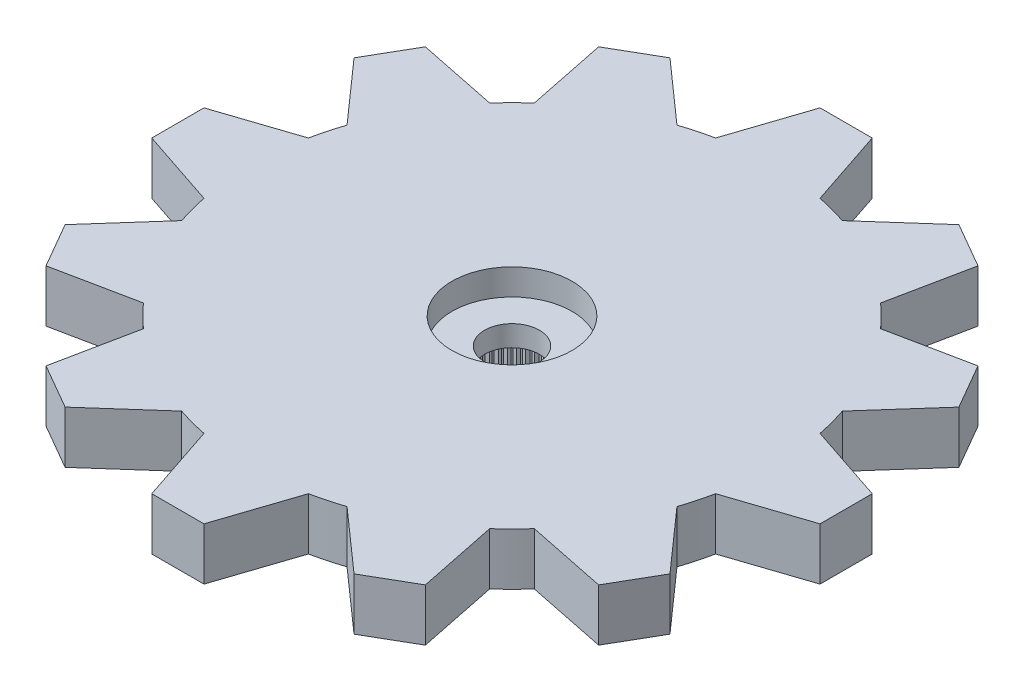
from build123d import *

# Parameters (mm, degrees)
RESSALTO_EXTRUS_O1_DEPTH = 1.4
ESBO_O2_R                = 3.45
RESSALTO_EXTRUS_O2_DEPTH = 2.4
FURO4_D                  = 1.2
PADR_O_LINEAR1_COUNT     = 6
PADR_O_LINEAR1_PITCH     = 2
PADR_OCIRCULAR2_COUNT    = 2
PADR_OCIRCULAR2_COPY_1_D = 1.2
PADR_OCIRCULAR2_COPY_2_D = 1.2
PADR_OCIRCULAR2_COPY_3_D = 1.2
PADR_OCIRCULAR2_COPY_4_D = 1.2
PADR_OCIRCULAR2_COPY_5_D = 1.2
FURO1_D                  = 4.95
FURO1_DEPTH              = 2
FURO2_D                  = 4.6
FURO2_DEPTH              = 1
FURO3_D                  = 2.1
RESSALTO_EXTRUS_O3_DEPTH = 2
PADR_OCIRCULAR1_COUNT    = 60
SKETCH2_W                = 33
SKETCH2_H                = 17
SKETCH2_R                = 3.45
CUT_EXTRUDE1_DEPTH       = 10
SKETCH3_R                = 10
SKETCH3_R_2              = 3.45
BOSS_EXTRUDE1_DEPTH      = 2
BOSS_EXTRUDE2_DEPTH      = 2


with BuildPart() as part:
    # Esboço1 → Ressalto-extrusão1 (new body)
    with BuildSketch(Plane(origin=(0, 0, 0), x_dir=(1, 0, 0), z_dir=(0, 1, 0))):
        with BuildLine():
            Line((-14.159121967, 1.99702088), (-2.209072203, 2.65))
            ThreePointArc((-2.209072203, 2.65), (3.45, 0), (-2.209072203, -2.65))
            Line((-2.209072203, -2.65), (-14.159121967, -1.99702088))
            ThreePointArc((-14.159121967, -1.99702088), (-16.05, 0), (-14.159121967, 1.99702088))
        make_face()
    ressalto_extrus_o1 = extrude(amount=-RESSALTO_EXTRUS_O1_DEPTH)

    # Esboço2 → Ressalto-extrusão2 (add)
    with BuildSketch(Plane.XZ.offset(1.4)):
        Circle(ESBO_O2_R)
    extrude(amount=RESSALTO_EXTRUS_O2_DEPTH)

    # Furo4 (through all)
    with Locations(Plane(origin=(0, 0, 0), x_dir=(1, 0, 0), z_dir=(0, 1, 0))):
        with Locations((-14.45, 0)):
            furo4 = Hole(FURO4_D / 2)

    # Padrão linear1: Furo4 ×6
    with Locations(*[(i * PADR_O_LINEAR1_PITCH, 0, 0) for i in range(1, PADR_O_LINEAR1_COUNT)]):
        add(furo4, mode=Mode.SUBTRACT)

    # PadrãoCircular2: Ressalto-extrusão1, Furo4 ×2 about axis
    padr_ocircular2_axis = Axis((0, 0, 0), (0, 1, 0))
    for i in range(1, PADR_OCIRCULAR2_COUNT):
        add(ressalto_extrus_o1.rotate(padr_ocircular2_axis, i * 360 / PADR_OCIRCULAR2_COUNT))
        add(furo4.rotate(padr_ocircular2_axis, i * 360 / PADR_OCIRCULAR2_COUNT), mode=Mode.SUBTRACT)

    # PadrãoCircular2 copy 1 (through all)
    with Locations(Plane(origin=(-2, 0, 0), x_dir=(-1, 0, 0), z_dir=(0, 1, 0))):
        with Locations((-14.45, 0)):
            Hole(PADR_OCIRCULAR2_COPY_1_D / 2)

    # PadrãoCircular2 copy 2 (through all)
    with Locations(Plane(origin=(-4, 0, 0), x_dir=(-1, 0, 0), z_dir=(0, 1, 0))):
        with Locations((-14.45, 0)):
            Hole(PADR_OCIRCULAR2_COPY_2_D / 2)

    # PadrãoCircular2 copy 3 (through all)
    with Locations(Plane(origin=(-6, 0, 0), x_dir=(-1, 0, 0), z_dir=(0, 1, 0))):
        with Locations((-14.45, 0)):
            Hole(PADR_OCIRCULAR2_COPY_3_D / 2)

    # PadrãoCircular2 copy 4 (through all)
    with Locations(Plane(origin=(-8, 0, 0), x_dir=(-1, 0, 0), z_dir=(0, 1, 0))):
        with Locations((-14.45, 0)):
            Hole(PADR_OCIRCULAR2_COPY_4_D / 2)

    # PadrãoCircular2 copy 5 (through all)
    with Locations(Plane(origin=(-10, 0, 0), x_dir=(-1, 0, 0), z_dir=(0, 1, 0))):
        with Locations((-14.45, 0)):
            Hole(PADR_OCIRCULAR2_COPY_5_D / 2)

    # Furo1
    with Locations(Plane(origin=(0, -3.8, 0), x_dir=(-1, 0, 0), z_dir=(0, -1, 0))):
        with Locations((0, 0)):
            Hole(FURO1_D / 2, depth=FURO1_DEPTH)

    # Furo2
    with Locations(Plane(origin=(0, 0, 0), x_dir=(1, 0, 0), z_dir=(0, 1, 0))):
        with Locations((0, 0)):
            Hole(FURO2_D / 2, depth=FURO2_DEPTH)

    # Furo3 (through all)
    with Locations(Plane(origin=(0, 0, 0), x_dir=(1, 0, 0), z_dir=(0, 1, 0))):
        with Locations((0, 0)):
            Hole(FURO3_D / 2)

    # Esboço11 → Ressalto-extrusão3 (add)
    with BuildSketch(Plane.XZ.offset(3.8)):
        with BuildLine():
            Line((-0.098056786, 2.473056786), (0, 2.375))
            Line((0, 2.375), (0.098056786, 2.473056786))
            ThreePointArc((0.098056786, 2.473056786), (0, 2.475), (-0.098056786, 2.473056786))
        make_face()
    ressalto_extrus_o3 = extrude(amount=-RESSALTO_EXTRUS_O3_DEPTH)

    # PadrãoCircular1: Ressalto-extrusão3 ×60 about axis
    padr_ocircular1_axis = Axis((0, 0, 0), (0, 1, 0))
    for i in range(1, PADR_OCIRCULAR1_COUNT):
        add(ressalto_extrus_o3.rotate(padr_ocircular1_axis, i * 360 / PADR_OCIRCULAR1_COUNT))

    # Sketch2 → Cut-Extrude1 (cut)
    with BuildSketch(Plane.XZ.offset(3.8)):
        Rectangle(SKETCH2_W, SKETCH2_H)
        Circle(SKETCH2_R, mode=Mode.SUBTRACT)
    extrude(amount=-CUT_EXTRUDE1_DEPTH, mode=Mode.SUBTRACT)

    # Sketch3 → Boss-Extrude1 (add)
    with BuildSketch(Plane(origin=(0, 0, 0), x_dir=(1, 0, 0), z_dir=(0, 1, 0))):
        Circle(SKETCH3_R)
        Circle(SKETCH3_R_2, mode=Mode.SUBTRACT)
    extrude(amount=-BOSS_EXTRUDE1_DEPTH)

    # Sketch5 → Boss-Extrude2 (add)
    with BuildSketch(Plane(origin=(0, 0, 0), x_dir=(1, 0, 0), z_dir=(0, 1, 0))):
        Polygon((-2, 9.797958971), (2, 9.797958971), (1, 12.797958971), (-1, 12.797958971), align=None)
        Polygon((5.532954082, 11.583357586), (3.166928678, 9.485281374), (6.631030293, 7.485281374), (7.265004889, 10.583357586), align=None)
        Polygon((10.583357586, 7.265004889), (7.485281374, 6.631030293), (9.485281374, 3.166928678), (11.583357586, 5.532954082), align=None)
        Polygon((12.797958971, 1), (9.797958971, 2), (9.797958971, -2), (12.797958971, -1), align=None)
        Polygon((11.583357586, -5.532954082), (9.485281374, -3.166928678), (7.485281374, -6.631030293), (10.583357586, -7.265004889), align=None)
        Polygon((7.265004889, -10.583357586), (6.631030293, -7.485281374), (3.166928678, -9.485281374), (5.532954082, -11.583357586), align=None)
        Polygon((1, -12.797958971), (2, -9.797958971), (-2, -9.797958971), (-1, -12.797958971), align=None)
        Polygon((-5.532954082, -11.583357586), (-3.166928678, -9.485281374), (-6.631030293, -7.485281374), (-7.265004889, -10.583357586), align=None)
        Polygon((-10.583357586, -7.265004889), (-7.485281374, -6.631030293), (-9.485281374, -3.166928678), (-11.583357586, -5.532954082), align=None)
        Polygon((-12.797958971, -1), (-9.797958971, -2), (-9.797958971, 2), (-12.797958971, 1), align=None)
        Polygon((-11.583357586, 5.532954082), (-9.485281374, 3.166928678), (-7.485281374, 6.631030293), (-10.583357586, 7.265004889), align=None)
        Polygon((-7.265004889, 10.583357586), (-6.631030293, 7.485281374), (-3.166928678, 9.485281374), (-5.532954082, 11.583357586), align=None)
    extrude(amount=-BOSS_EXTRUDE2_DEPTH)


solid = part.part
